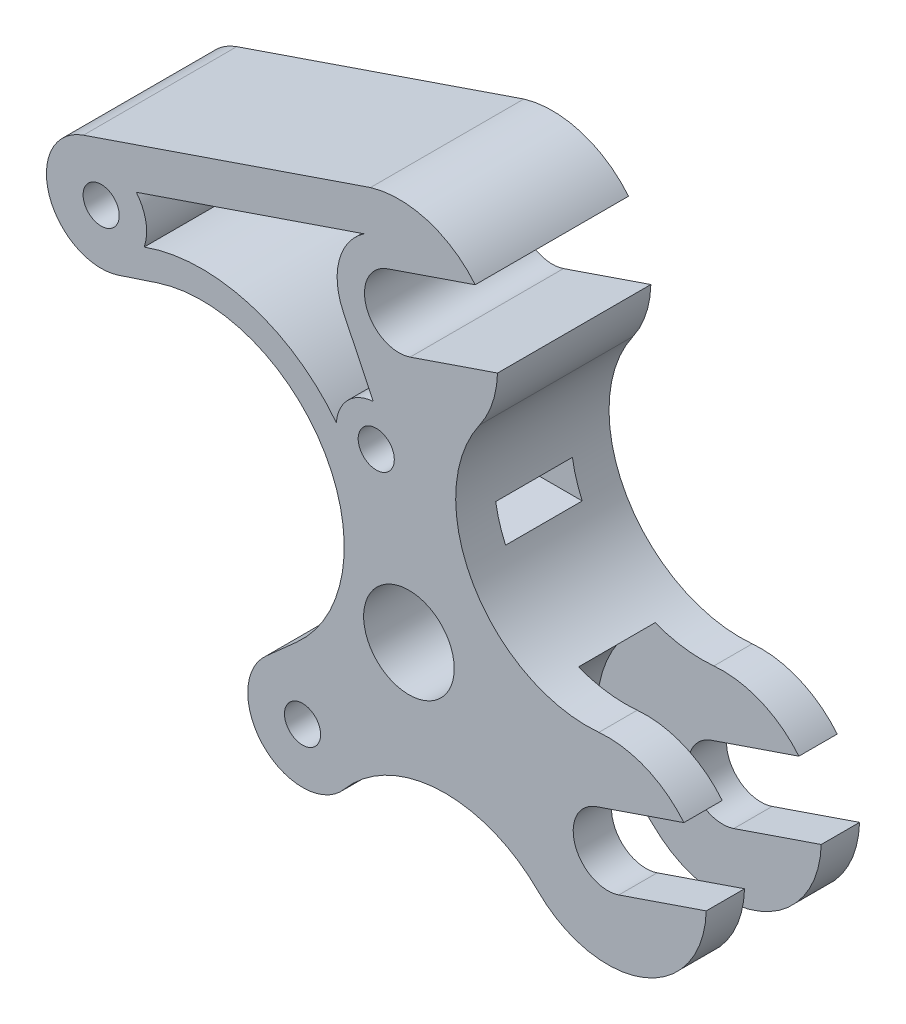
from build123d import *

# Parameters (mm, degrees)
SKETCH1_R               = 1.65
BOSS_EXTRUDE1_DEPTH     = 14
CUT_EXTRUDE1_DEPTH      = 3.5
CUT_EXTRUDE1_DEPTH_BACK = 3.5
SKETCH4_R               = 4.134785872
CUT_EXTRUDE2_DEPTH      = 15


with BuildPart() as part:
    # Sketch1 → Boss-Extrude1 (new body)
    with BuildSketch(Plane.XY):
        with BuildLine():
            Line((-4.072673183, 12.345579498), (-7.625975393, 11.173383521))
            ThreePointArc((-7.625975393, 11.173383521), (-13.932101619, 14.329478478), (-10.810338029, 20.652670351))
            Line((-10.810338029, 20.652670351), (15.398053767, 29.615676166))
            ThreePointArc((15.398053767, 29.615676166), (20.618433164, 29.610679867), (24.957842791, 26.708627129))
            Line((24.957842791, 26.708627129), (16.98069158, 23.980521824))
            ThreePointArc((16.98069158, 23.980521824), (15.019478176, 19.98069158), (19.01930842, 18.019478176))
            Line((19.01930842, 18.019478176), (26.996459631, 20.747583481))
            ThreePointArc((26.996459631, 20.747583481), (26.541449303, 18.163868162), (25.360666834, 15.821140689))
            ThreePointArc((25.360666834, 15.821140689), (24.782584433, 2.915994941), (36.247809691, -3.035943889))
            ThreePointArc((36.247809691, -3.035943889), (40.533104807, -3.700175716), (44.010342791, -6.291270882))
            Line((44.010342791, -6.291270882), (36.03319158, -9.019376187))
            ThreePointArc((36.03319158, -9.019376187), (34.071978176, -13.019206432), (38.07180842, -14.980419835))
            Line((38.07180842, -14.980419835), (46.048959631, -12.25231453))
            ThreePointArc((46.048959631, -12.25231453), (40.381510061, -20.361577987), (30.691295483, -18.366614362))
            ThreePointArc((30.691295483, -18.366614362), (21.686652044, -14.866973588), (13.021006186, -19.137532201))
            ThreePointArc((13.021006186, -19.137532201), (5.710138119, -19.509709901), (5.863446279, -12.190980179))
            Line((5.863446279, -12.190980179), (8.655248878, -9.699828187))
            ThreePointArc((8.655248878, -9.699828187), (11.258330249, 6.5), (-4.072673183, 12.345579498))
        make_face()
        with Locations((-9.192388155, 15.921683328)):
            Circle(SKETCH1_R, mode=Mode.SUBTRACT)
        with Locations((15.921683328, 9.192388155)):
            Circle(SKETCH1_R, mode=Mode.SUBTRACT)
        with Locations((9.192388155, -15.921683328)):
            Circle(SKETCH1_R, mode=Mode.SUBTRACT)
    extrude(amount=BOSS_EXTRUDE1_DEPTH)

    # Sketch3 → Cut-Extrude1 (cut, two sides)
    with BuildSketch(Plane.XY.offset(7)) as cut_extrude1_sk:
        with BuildLine():
            Line((0, 7), (37.0525, 7))
            Line((37.0525, 7), (37.0525, 4))
            Line((37.0525, 4), (5.744562647, 4))
            ThreePointArc((5.744562647, 4), (6.839579176, -1.490019025), (3.560144623, -6.027053199))
            Line((3.560144623, -6.027053199), (26.472773451, -16.50760099))
            ThreePointArc((26.472773451, -16.50760099), (45.290154871, -3.975495091), (32.268920997, -22.457783645))
            Line((32.268920997, -22.457783645), (-2.911743741, -6.365669516))
            ThreePointArc((-2.911743741, -6.365669516), (-6.839579176, 1.490019025), (0, 7))
        make_face()
    extrude(amount=CUT_EXTRUDE1_DEPTH, mode=Mode.SUBTRACT)
    extrude(cut_extrude1_sk.sketch, amount=-CUT_EXTRUDE1_DEPTH_BACK, mode=Mode.SUBTRACT)

    # Sketch4 → Cut-Extrude2 (cut, through all)
    with BuildSketch(Plane.XY.offset(14)):
        with Locations((18.906044872, -4.601778811)):
            Circle(SKETCH4_R)
        with BuildLine():
            Line((15.638639586, 12.831397119), (12.901157572, 18.566010293))
            ThreePointArc((12.901157572, 18.566010293), (12.545106314, 22.471949344), (14.817713576, 25.668570778))
            Line((14.817713576, 25.668570778), (-5.984422938, 18.554449775))
            ThreePointArc((-5.984422938, 18.554449775), (-5.108522805, 16.659615437), (-5.265913096, 14.578071178))
            ThreePointArc((-5.265913096, 14.578071178), (4.343025459, 14.879117241), (12.281235493, 9.456281234))
            ThreePointArc((12.281235493, 9.456281234), (13.333962642, 11.766529109), (15.638639586, 12.831397119))
        make_face()
    extrude(amount=-CUT_EXTRUDE2_DEPTH, mode=Mode.SUBTRACT)


solid = part.part
